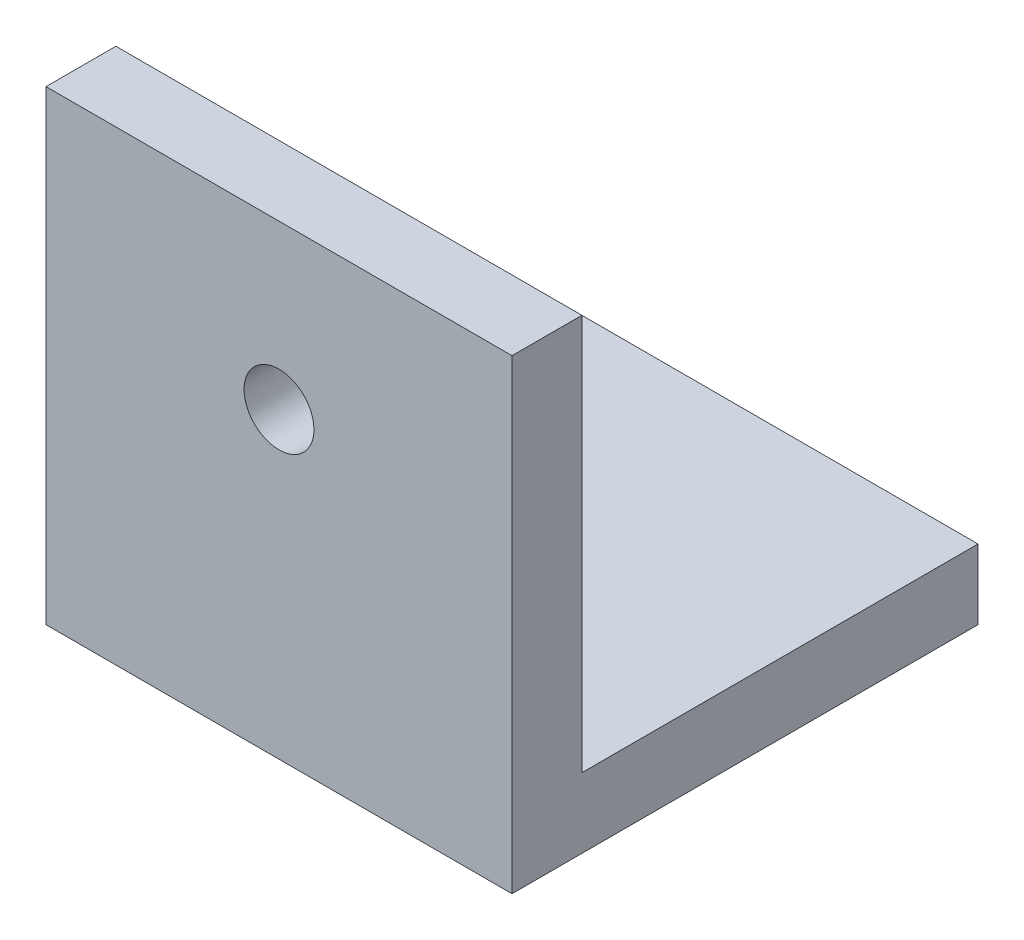
from build123d import *

# Parameters (mm, degrees)
SKETCH1_W           = 100
SKETCH1_H           = 100
SKETCH1_R           = 7.5
BOSS_EXTRUDE1_DEPTH = 15
SKETCH2_W           = 85
SKETCH2_H           = 15
BOSS_EXTRUDE2_DEPTH = 100


with BuildPart() as part:
    # Sketch1 → Boss-Extrude1 (new body)
    with BuildSketch(Plane.XY):
        Rectangle(SKETCH1_W, SKETCH1_H)
        with Locations((0, 15)):
            Circle(SKETCH1_R, mode=Mode.SUBTRACT)
    extrude(amount=BOSS_EXTRUDE1_DEPTH)

    # Sketch2 → Boss-Extrude2 (add)
    with BuildSketch(Plane(origin=(50, 0, 0), x_dir=(0, 0, -1), z_dir=(1, 0, 0))):
        with Locations((42.5, -42.5)):
            Rectangle(SKETCH2_W, SKETCH2_H)
    extrude(amount=-BOSS_EXTRUDE2_DEPTH)


solid = part.part
